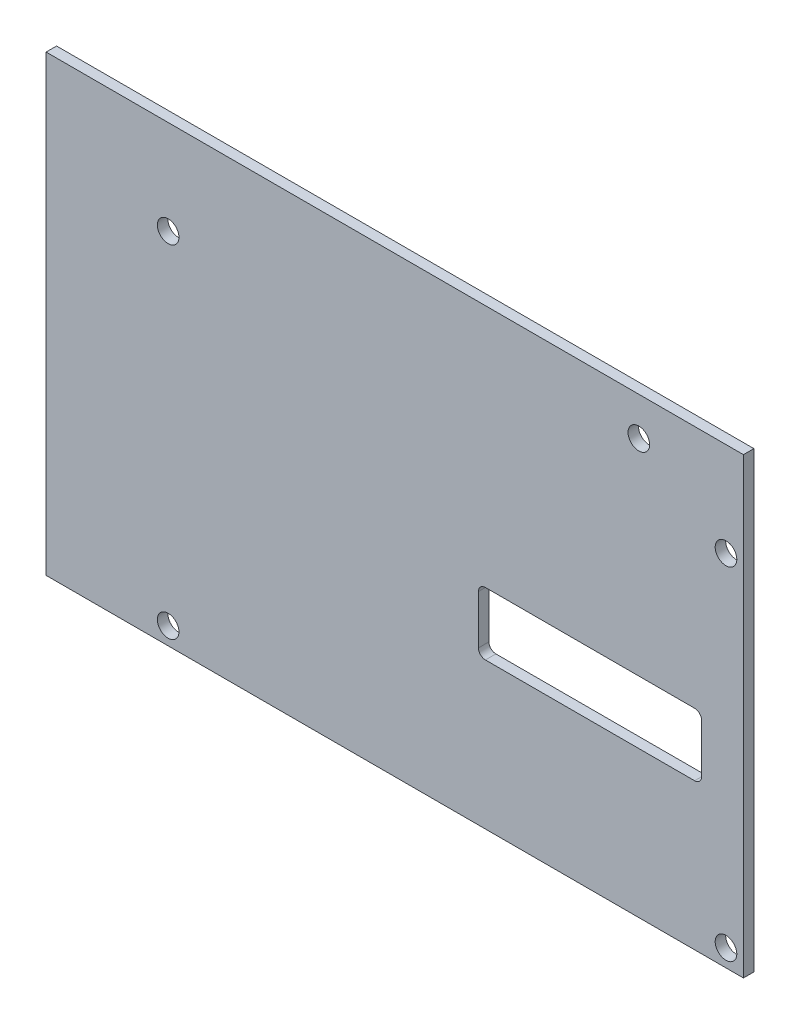
from build123d import *

# Parameters (mm, degrees)
SKETCH_1_W      = 100
SKETCH_1_H      = 65
SKETCH_1_R      = 1.55
EXTRUDE_1_DEPTH = 1.5


with BuildPart() as part:
    # Эскиз1 → Бобышка-Вытянуть1 (new body)
    with BuildSketch(Plane.XY):
        with Locations((50, 32.5)):
            Rectangle(SKETCH_1_W, SKETCH_1_H)
        with Locations((17.5, 51.5)):
            Circle(SKETCH_1_R, mode=Mode.SUBTRACT)
        with Locations((97.5, 51.5)):
            Circle(SKETCH_1_R, mode=Mode.SUBTRACT)
        with Locations((97.5, 2.5)):
            Circle(SKETCH_1_R, mode=Mode.SUBTRACT)
        with Locations((17.5, 2.5)):
            Circle(SKETCH_1_R, mode=Mode.SUBTRACT)
        with Locations((85, 59.5)):
            Circle(SKETCH_1_R, mode=Mode.SUBTRACT)
        with BuildLine():
            Line((63, 30), (93, 30))
            ThreePointArc((93, 30), (93.707106781, 29.707106781), (94, 29))
            Line((94, 29), (94, 22))
            ThreePointArc((94, 22), (93.707106781, 21.292893219), (93, 21))
            Line((93, 21), (63, 21))
            ThreePointArc((63, 21), (62.292893219, 21.292893219), (62, 22))
            Line((62, 22), (62, 29))
            ThreePointArc((62, 29), (62.292893219, 29.707106781), (63, 30))
        make_face(mode=Mode.SUBTRACT)
    extrude(amount=EXTRUDE_1_DEPTH)


solid = part.part
